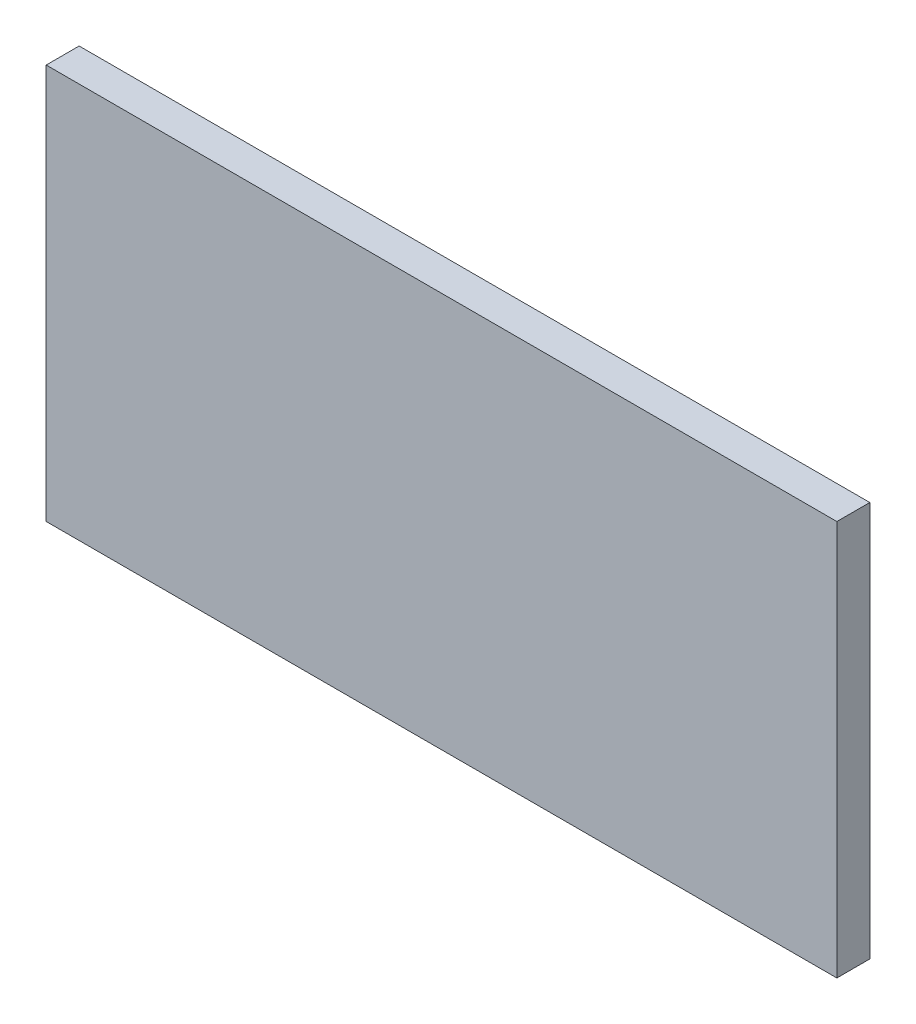
from build123d import *

# Parameters (mm, degrees)
SKETCH1_W           = 6.35
SKETCH1_H           = 76.2
BOSS_EXTRUDE1_DEPTH = 152.4


with BuildPart() as part:
    # Sketch1 → Boss-Extrude1 (new body)
    with BuildSketch(Plane(origin=(0, 0, 0), x_dir=(0, 0, -1), z_dir=(1, 0, 0))):
        Rectangle(SKETCH1_W, SKETCH1_H)
    extrude(amount=BOSS_EXTRUDE1_DEPTH)


solid = part.part
